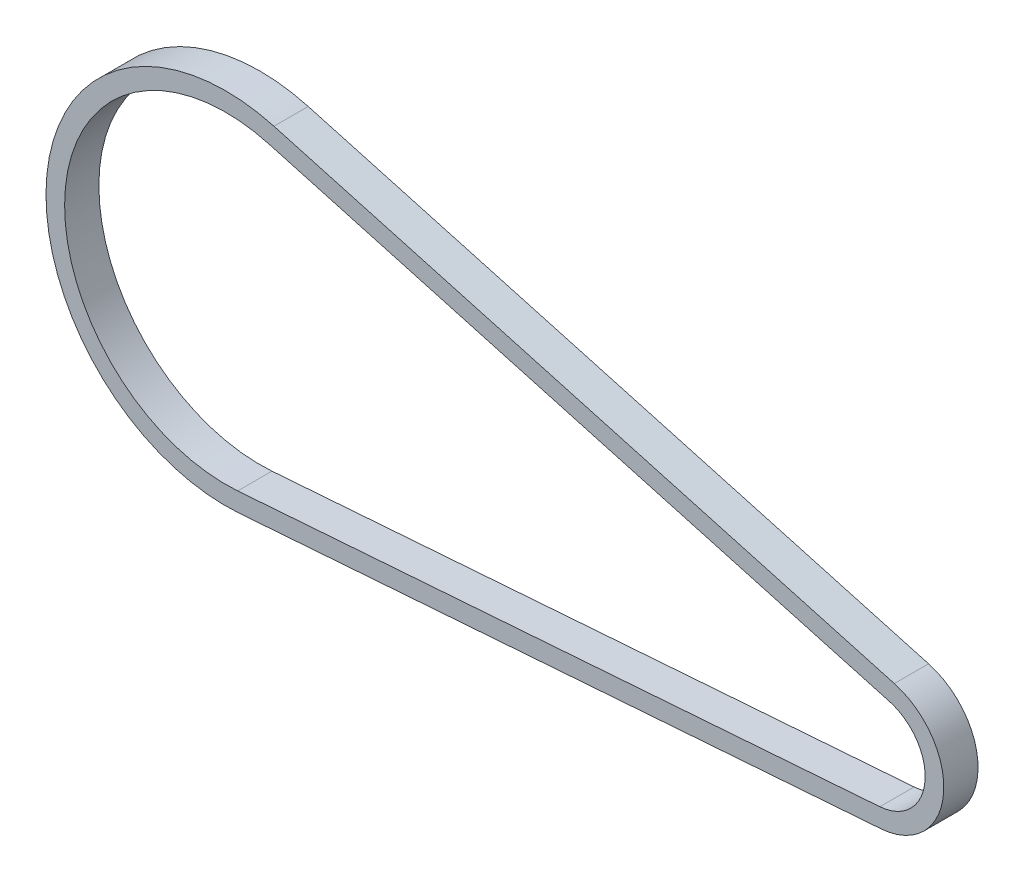
from build123d import *

# Parameters (mm, degrees)
SKETCH3_W = 25.4
SKETCH3_H = 13.8


with BuildPart() as part:
    # Sweep1: sweep along a path in Sketch2
    with BuildLine(Plane.XY) as sweep1_path:
        Line((33.86003419, 121.796767504), (493.886560577, -6.092619308))
        ThreePointArc((493.886560577, -6.092619308), (525.300492459, -51.958667828), (485.509770578, -90.781701911))
        Line((485.509770578, -90.781701911), (9.342960491, -126.070074081))
        ThreePointArc((9.342960491, -126.070074081), (-125.801897747, 12.443352159), (33.86003419, 121.796767504))
    # Sketch3 → Sweep1 (sweep)
    with BuildSketch(Plane(origin=(0, 0, 0), x_dir=(0, 0, -1), z_dir=(1, 0, 0))):
        with Locations((0, 126.4158)):
            Rectangle(SKETCH3_W, SKETCH3_H)
    sweep(path=sweep1_path.line)


solid = part.part
